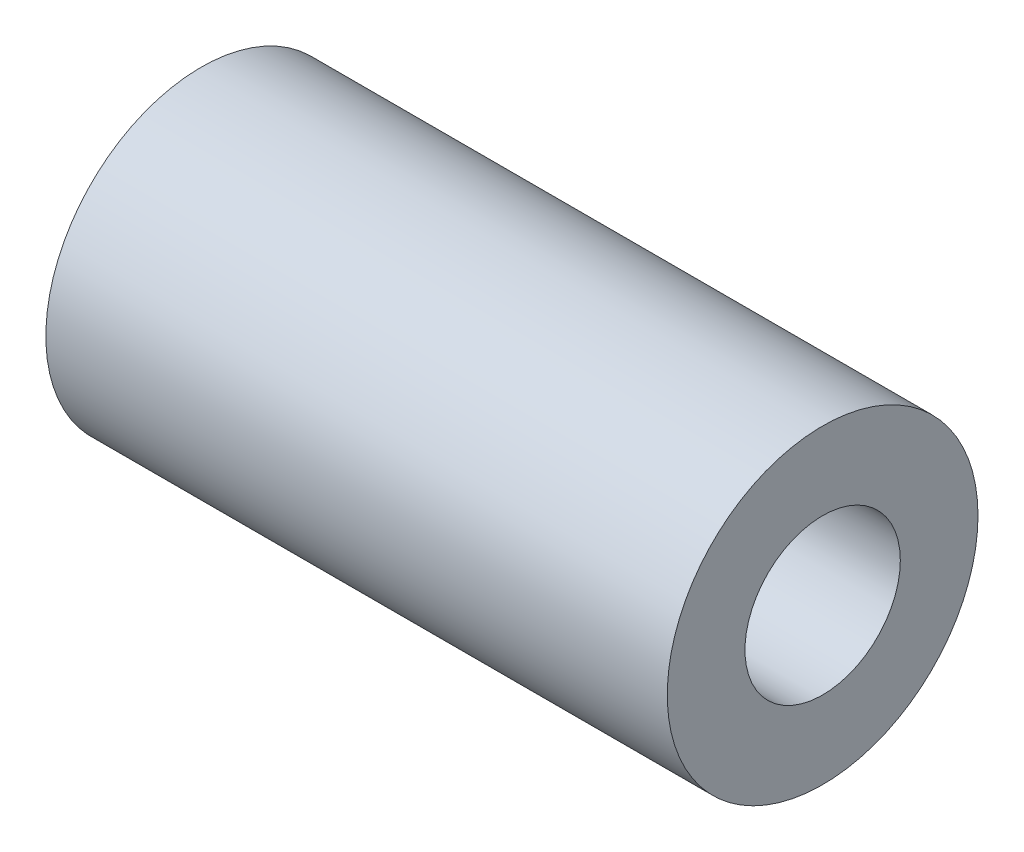
from build123d import *

# Parameters (mm, degrees)
SKETCH1_R           = 5
SKETCH1_R_2         = 2.5
BOSS_EXTRUDE1_DEPTH = 20


with BuildPart() as part:
    # Sketch1 → Boss-Extrude1 (new body)
    with BuildSketch(Plane(origin=(0, 0, 0), x_dir=(0, 0, -1), z_dir=(1, 0, 0))):
        Circle(SKETCH1_R)
        Circle(SKETCH1_R_2, mode=Mode.SUBTRACT)
    extrude(amount=BOSS_EXTRUDE1_DEPTH)


solid = part.part
